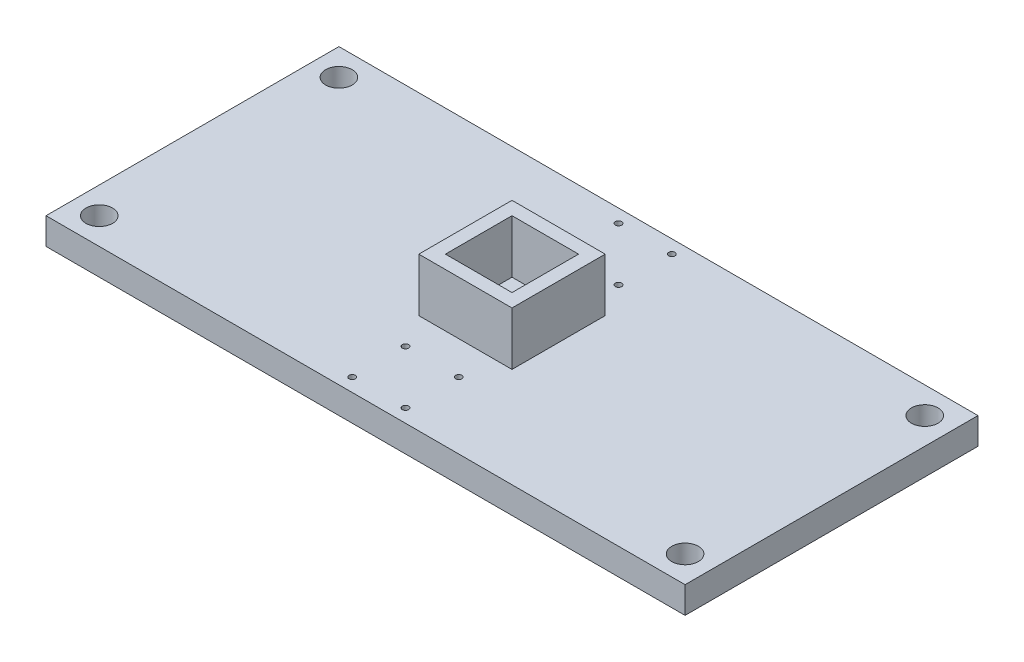
from build123d import *

# Parameters (mm, degrees)
SKETCH1_W           = 304.8
SKETCH1_H           = 139.7
BOSS_EXTRUDE1_DEPTH = 12.7
SKETCH5_R           = 1.5
SKETCH5_R_2         = 6.35
CUT_EXTRUDE2_DEPTH  = 13.7
SKETCH8_W           = 44.45
SKETCH8_H           = 44.45
SKETCH8_W_2         = 31.75
SKETCH8_H_2         = 31.75
BOSS_EXTRUDE3_DEPTH = 25.4


with BuildPart() as part:
    # Sketch1 → Boss-Extrude1 (new body)
    with BuildSketch(Plane(origin=(0, 0, 0), x_dir=(1, 0, 0), z_dir=(0, 1, 0))):
        with Locations((152.4, 69.85)):
            Rectangle(SKETCH1_W, SKETCH1_H)
    extrude(amount=BOSS_EXTRUDE1_DEPTH)

    # Sketch5 → Cut-Extrude2 (cut, through all)
    with BuildSketch(Plane(origin=(0, 12.7, 0), x_dir=(1, 0, 0), z_dir=(0, 1, 0))):
        with Locations((165.1, 6.35)):
            Circle(SKETCH5_R)
        with Locations((165.1, 31.75)):
            Circle(SKETCH5_R)
        with Locations((139.7, 31.75)):
            Circle(SKETCH5_R)
        with Locations((12.7, 12.7)):
            Circle(SKETCH5_R_2)
        with Locations((139.7, 6.35)):
            Circle(SKETCH5_R)
        with Locations((292.1, 12.7)):
            Circle(SKETCH5_R_2)
    cut_extrude2 = extrude(amount=-CUT_EXTRUDE2_DEPTH, mode=Mode.SUBTRACT)

    # Sketch8 → Boss-Extrude3 (add)
    with BuildSketch(Plane(origin=(0, 12.7, 0), x_dir=(1, 0, 0), z_dir=(0, 1, 0))):
        with Locations((152.4, 69.85)):
            Rectangle(SKETCH8_W, SKETCH8_H)
        with Locations((152.4, 69.85)):
            Rectangle(SKETCH8_W_2, SKETCH8_H_2, mode=Mode.SUBTRACT)
    extrude(amount=BOSS_EXTRUDE3_DEPTH)

    # Mirror1: Cut-Extrude2 across plane
    add(cut_extrude2.mirror(Plane.XY.offset(-69.85)), mode=Mode.SUBTRACT)


solid = part.part
